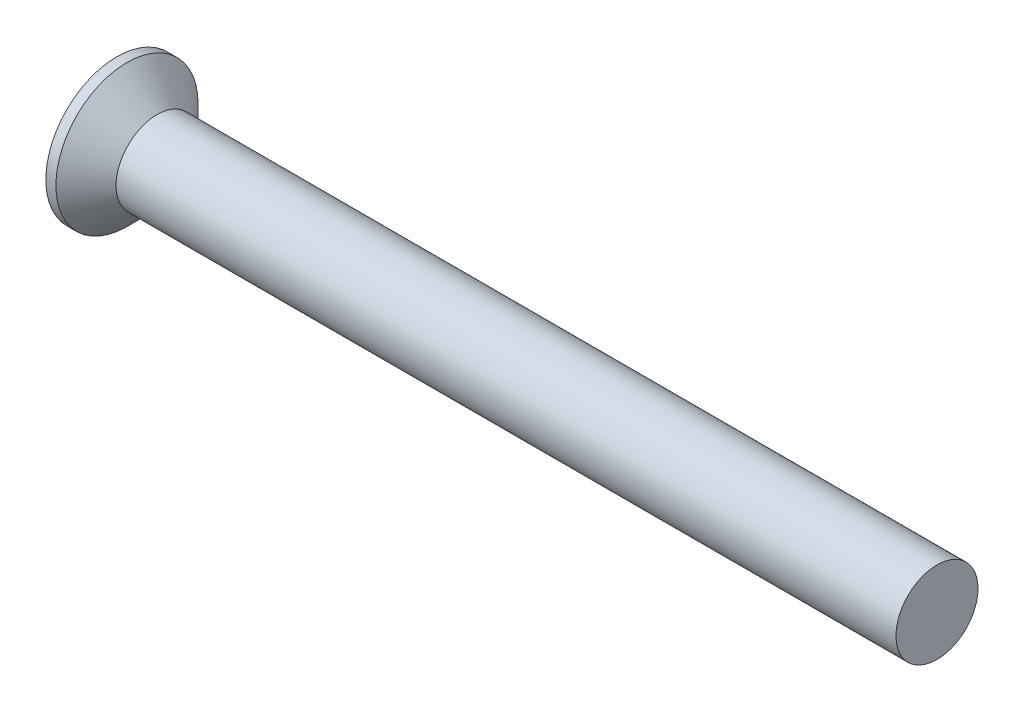
from build123d import *

# Parameters (mm, degrees)
BASETOP_FACE_RADIUS = 2.6
BASETOP_HEIGHT      = 0.7
CROSSRECESS_DEPTH   = 0.825
DRAFT9_ANGLE        = -30
FILLET5_R           = 0.3


with BuildPart() as part:
    # Sketch1 → Base (revolve)
    with BuildSketch(Plane.XY):
        Polygon((30, 1.5), (2.737867966, 1.5), (1.467367966, 1.5), (0.367367966, 2.6), (0, 2.6), (0, 0), (30, 0), align=None)
    revolve(axis=Axis((4.515812911, 0, 0), (-1, 0, 0)))

    # BaseTop: a dome of height H over a round flat face of radius A is a cap of a sphere of radius (A * A + H * H) / (2 * H)
    basetop_r = (BASETOP_FACE_RADIUS * BASETOP_FACE_RADIUS + BASETOP_HEIGHT * BASETOP_HEIGHT) / (2 * BASETOP_HEIGHT)
    basetop_base = Plane((0, 0, 0), z_dir=(-1, 0, 0))
    with Locations(basetop_base.offset(BASETOP_HEIGHT - basetop_r)):
        basetop_ball = Sphere(basetop_r, mode=Mode.PRIVATE)
    add(split(basetop_ball, bisect_by=basetop_base, keep=Keep.TOP, mode=Mode.PRIVATE))

    # Sketch6 → CrossRecess (cut)
    with BuildSketch(Plane.ZY.offset(0.7)):
        Polygon((0.34, 0.34), (0.34, 1.7), (-0.34, 1.7), (-0.34, 0.34), (-1.7, 0.34), (-1.7, -0.34), (-0.34, -0.34), (-0.34, -1.7), (0.34, -1.7), (0.34, -0.34), (1.7, -0.34), (1.7, 0.34), align=None)
    extrude(amount=-CROSSRECESS_DEPTH, mode=Mode.SUBTRACT)

    # Draft9
    draft9_faces = [part.faces().sort_by_distance(p)[0] for p in [
        (-0.14204754, 0, -1.7),
        (-0.14204754, -1.7, 0),
        (-0.14204754, 0, 1.7),
        (-0.14204754, 1.7, 0),
    ]]
    draft(draft9_faces, Plane(origin=(-0.7, 0, 0), x_dir=(0, 0, 1), z_dir=(1, 0, 0)), DRAFT9_ANGLE)

    # Fillet5
    fillet5_edges = [part.edges().sort_by_distance(p)[0] for p in [
        (-0.27631446, 0.34, -0.34),
        (-0.27631446, 0.34, 0.34),
        (-0.27631446, -0.34, 0.34),
        (-0.27631446, -0.34, -0.34),
    ]]
    fillet(fillet5_edges, radius=FILLET5_R)


solid = part.part
